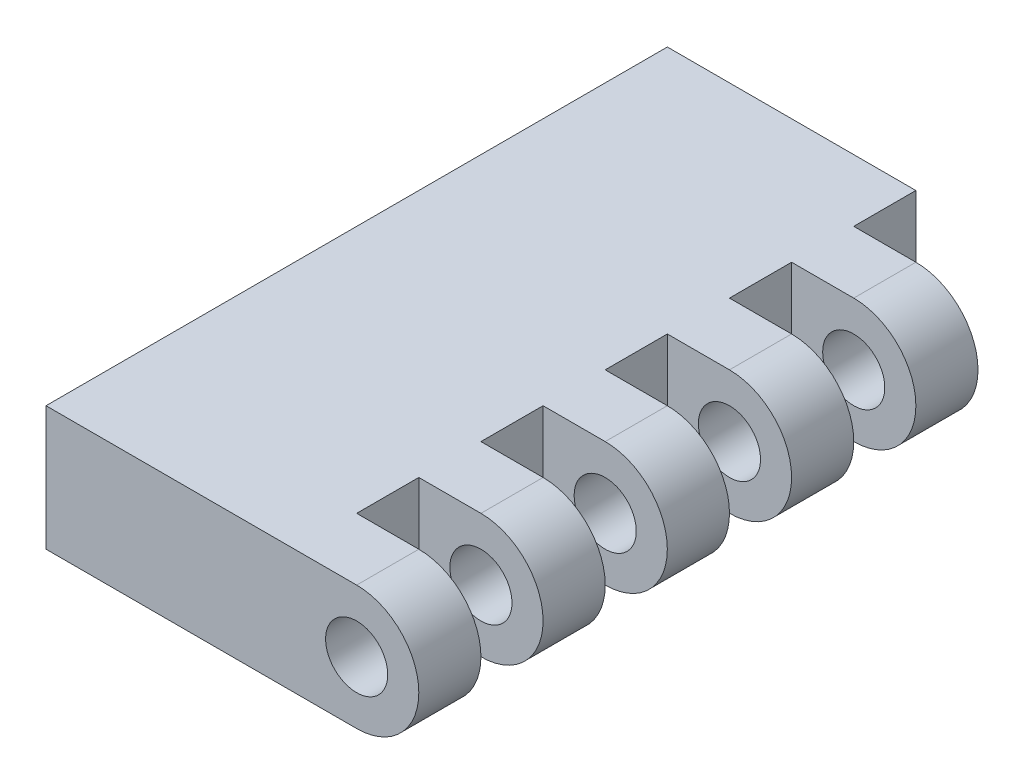
from build123d import *

# Parameters (mm, degrees)
SKETCH1_R           = 0.127
BOSS_EXTRUDE1_DEPTH = 2.54
SKETCH2_W           = 0.508
SKETCH2_H           = 0.254
CUT_EXTRUDE1_DEPTH  = 1.508


with BuildPart() as part:
    # Sketch1 → Boss-Extrude1 (new body)
    with BuildSketch(Plane.XY):
        with BuildLine():
            Line((0, 0.254), (-1.27, 0.254))
            Line((-1.27, 0.254), (-1.27, -0.254))
            Line((-1.27, -0.254), (0, -0.254))
            ThreePointArc((0, -0.254), (0.254, 0), (0, 0.254))
        make_face()
        Circle(SKETCH1_R, mode=Mode.SUBTRACT)
    extrude(amount=BOSS_EXTRUDE1_DEPTH)

    # Sketch2 → Cut-Extrude1 (cut, through all)
    with BuildSketch(Plane(origin=(0, 0.254, 0), x_dir=(1, 0, 0), z_dir=(0, 1, 0))):
        with Locations((0, -0.127)):
            Rectangle(SKETCH2_W, SKETCH2_H)
        with Locations((0, -0.635)):
            Rectangle(SKETCH2_W, SKETCH2_H)
        with Locations((0, -1.143)):
            Rectangle(SKETCH2_W, SKETCH2_H)
        with Locations((0, -1.651)):
            Rectangle(SKETCH2_W, SKETCH2_H)
        with Locations((0, -2.159)):
            Rectangle(SKETCH2_W, SKETCH2_H)
    extrude(amount=-CUT_EXTRUDE1_DEPTH, mode=Mode.SUBTRACT)


solid = part.part
